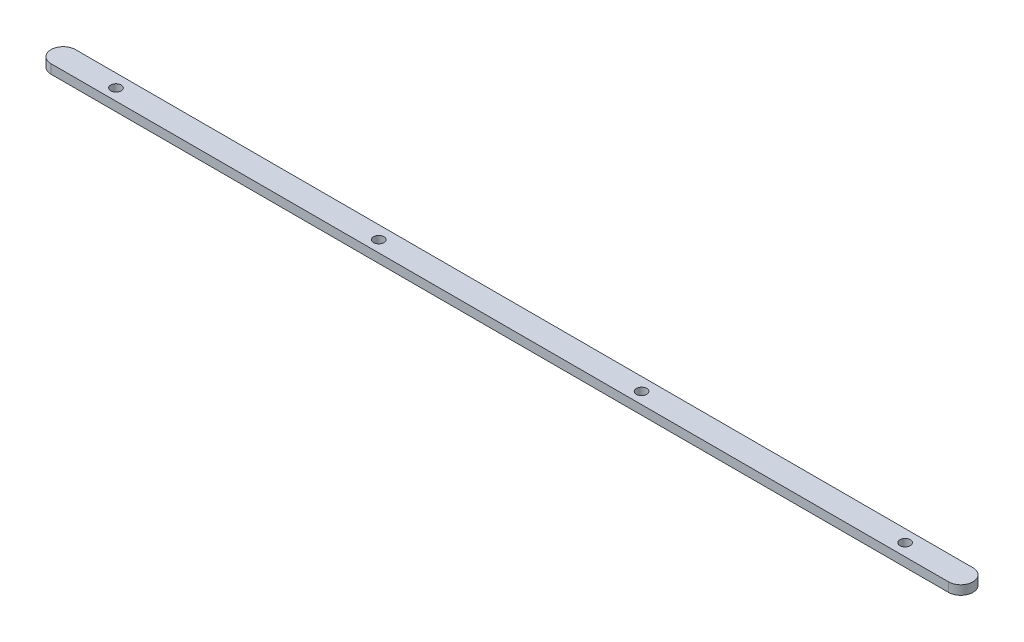
from build123d import *

# Parameters (mm, degrees)
SKETCH2_R           = 1.7
BOSS_EXTRUDE1_DEPTH = 3


with BuildPart() as part:
    # Sketch2 → Boss-Extrude1 (new body)
    with BuildSketch(Plane(origin=(0, 0, 0), x_dir=(1, 0, 0), z_dir=(0, 1, 0))):
        with BuildLine():
            Line((-129.94436932, 0.184481604), (163.75498068, 0.184481604))
            ThreePointArc((163.75498068, 0.184481604), (166.583407805, 1.356054479), (167.75498068, 4.184481604))
            ThreePointArc((167.75498068, 4.184481604), (166.583407805, 7.012908729), (163.75498068, 8.184481604))
            Line((163.75498068, 8.184481604), (-129.94436932, 8.184481604))
            ThreePointArc((-129.94436932, 8.184481604), (-132.772796445, 7.012908729), (-133.94436932, 4.184481604))
            ThreePointArc((-133.94436932, 4.184481604), (-132.772796445, 1.356054479), (-129.94436932, 0.184481604))
        make_face()
        with Locations((145.55563068, 4.184481604)):
            Circle(SKETCH2_R, mode=Mode.SUBTRACT)
        with Locations((59.55563068, 3.934481604)):
            Circle(SKETCH2_R, mode=Mode.SUBTRACT)
        with Locations((-112.44436932, 3.934481604)):
            Circle(SKETCH2_R, mode=Mode.SUBTRACT)
        with Locations((-26.44436932, 3.934481604)):
            Circle(SKETCH2_R, mode=Mode.SUBTRACT)
    extrude(amount=BOSS_EXTRUDE1_DEPTH)


solid = part.part
